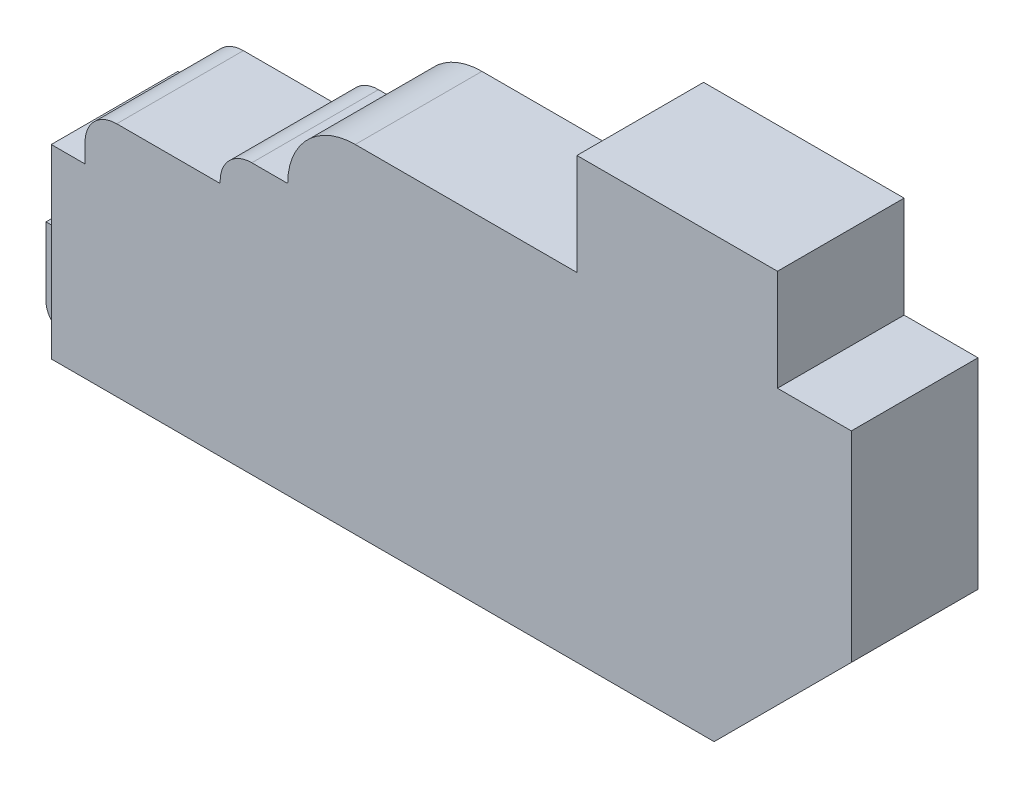
from build123d import *

# Parameters (mm, degrees)
EXTRUDE1_DEPTH      = 9.525
EXTRUDE1_DEPTH_BACK = 9.525
SKETCH3_R           = 3.5687
EXTRUDE2_DEPTH      = 12.7
CUT_EXTRUDE1_DEPTH  = 4.7625


with BuildPart() as part:
    # Sketch1 → Extrude1 (new, two sides)
    with BuildSketch(Plane.XY) as extrude1_sk:
        with BuildLine():
            Line((-1.5875, 0), (99.695, 0))
            Line((99.695, 0), (120.3325, 20.6375))
            Line((120.3325, 20.6375), (120.3325, 50.8))
            Line((120.3325, 50.8), (109.22, 50.8))
            Line((109.22, 50.8), (109.22, 66.04))
            Line((109.22, 66.04), (79.0575, 66.04))
            Line((79.0575, 66.04), (79.0575, 50.8))
            Line((79.0575, 50.8), (45.72, 50.8))
            ThreePointArc((45.72, 50.8), (38.535795103, 47.824204897), (35.56, 40.64))
            Line((35.56, 40.64), (30.1625, 40.64))
            ThreePointArc((30.1625, 40.64), (26.794903955, 39.245096045), (25.4, 35.8775))
            Line((25.4, 35.8775), (25.4, 35.56))
            Line((25.4, 35.56), (9.8425, 35.56))
            ThreePointArc((9.8425, 35.56), (6.474903955, 34.165096045), (5.08, 30.7975))
            Line((5.08, 30.7975), (5.08, 27.94))
            Line((5.08, 27.94), (0, 27.94))
            Line((0, 27.94), (0, 13.49375))
            Line((0, 13.49375), (-4.7625, 13.49375))
            Line((-4.7625, 13.49375), (-4.7625, 3.175))
            ThreePointArc((-4.7625, 3.175), (-3.83256403, 0.92993597), (-1.5875, 0))
        make_face()
    extrude(amount=EXTRUDE1_DEPTH)
    extrude(extrude1_sk.sketch, amount=-EXTRUDE1_DEPTH_BACK)


with BuildPart() as body_2:
    # Sketch3 → Extrude2 (new body)
    with BuildSketch(Plane.ZY):
        with Locations((0, 20.6502)):
            Circle(SKETCH3_R)
    extrude(amount=-EXTRUDE2_DEPTH)


with BuildPart() as part_1:
    add(part.part)

    # Combine1: cut body 2
    add(body_2.part, mode=Mode.SUBTRACT)

    # Sketch4 → Cut-Extrude1 (cut)
    with BuildSketch(Plane.ZY.offset(4.7625)):
        Polygon((-9.525, 20.0025), (-9.525, 0), (-5.55625, 0), (-5.55625, 16.03375), align=None)
        Polygon((5.55625, 0), (9.525, 0), (9.525, 20.0025), (5.55625, 16.03375), align=None)
    extrude(amount=-CUT_EXTRUDE1_DEPTH, mode=Mode.SUBTRACT)


solid = part_1.part
